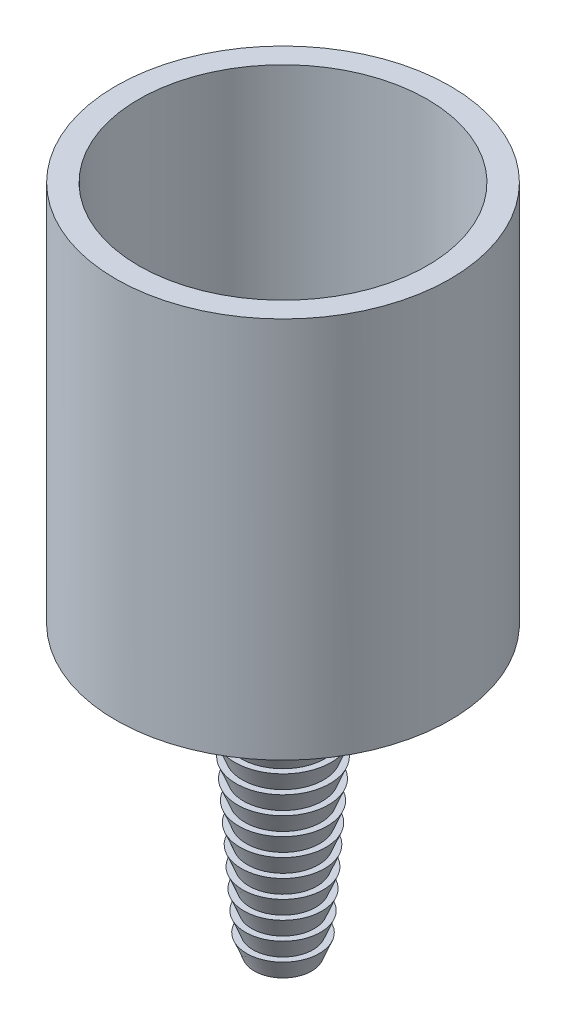
from build123d import *

# Parameters (mm, degrees)
SKETCH_1_R          = 17.5
EXTRUDE_1_DEPTH     = 40
SKETCH_2_R          = 15.1
CUT_EXTRUDE_1_DEPTH = 35
SKETCH_5_R          = 1.75
CUT_EXTRUDE_2_DEPTH = 71
SKETCH_8_R          = 17.5
EXTRUDE_2_DEPTH     = 5
SKETCH_11_R         = 1
CUT_EXTRUDE_3_DEPTH = 5


with BuildPart() as part:
    # 草图1 → 凸台-拉伸1 (new body)
    with BuildSketch(Plane(origin=(0, 0, 0), x_dir=(1, 0, 0), z_dir=(0, 1, 0))):
        Circle(SKETCH_1_R)
    extrude(amount=EXTRUDE_1_DEPTH)

    # 草图2 → 切除-拉伸1 (cut)
    with BuildSketch(Plane(origin=(0, 40, 0), x_dir=(1, 0, 0), z_dir=(0, 1, 0))):
        Circle(SKETCH_2_R)
    extrude(amount=-CUT_EXTRUDE_1_DEPTH, mode=Mode.SUBTRACT)

    # 草图4 → 旋转1 (revolve)
    with BuildSketch(Plane.XY):
        Polygon((0, 0), (0, -30), (3, -30), (3.8, -28), (3.139853624, -28), (3.939512947, -26.004871899), (3.279366571, -26.004871899), (4.079025895, -24.009743799), (3.418879519, -24.009743799), (4.218538842, -22.014615698), (3.558392466, -22.014615698), (4.35805179, -20.019487598), (3.697905414, -20.019487598), (4.497564737, -18.024359497), (3.837418361, -18.024359497), (4.637077685, -16.029231397), (3.976931309, -16.029231397), (4.776590632, -14.034103296), (4.116444256, -14.034103296), (4.91610358, -12.038975196), (4.255957204, -12.038975196), (5.055616527, -10.043847095), (4.395470151, -10.043847095), (5.195129475, -8.048718995), (4.534983099, -8.048718995), (5.334642422, -6.053590894), (4.674496046, -6.053590894), (5.47415537, -4.058462794), (4.814008994, -4.058462794), (17.5, 0), align=None)
    revolve(axis=Axis((0, 0, 0), (0, -1, 0)))

    # 草图5 → 切除-拉伸2 (cut, through all)
    with BuildSketch(Plane.XZ.offset(30)):
        Circle(SKETCH_5_R)
    extrude(amount=-CUT_EXTRUDE_2_DEPTH, mode=Mode.SUBTRACT)

    # 草图8 → 凸台-拉伸2 (add)
    with BuildSketch(Plane(origin=(0, 10, 0), x_dir=(1, 0, 0), z_dir=(0, 1, 0))):
        Circle(SKETCH_8_R)
    extrude(amount=EXTRUDE_2_DEPTH)

    # 草图11 → 切除-拉伸3 (cut)
    with BuildSketch(Plane(origin=(0, 15, 0), x_dir=(1, 0, 0), z_dir=(0, 1, 0))):
        with Locations((0, 9)):
            Circle(SKETCH_11_R)
        with Locations((3.660629788, 8.221909119)):
            Circle(SKETCH_11_R)
        with Locations((6.688303429, 6.022175457)):
            Circle(SKETCH_11_R)
        with Locations((8.559508647, 2.781152949)):
            Circle(SKETCH_11_R)
        with Locations((8.950697058, -0.940756169)):
            Circle(SKETCH_11_R)
        with Locations((7.794228634, -4.5)):
            Circle(SKETCH_11_R)
        with Locations((5.290067271, -7.281152949)):
            Circle(SKETCH_11_R)
        with Locations((1.871205217, -8.803328407)):
            Circle(SKETCH_11_R)
        with Locations((-1.871205217, -8.803328407)):
            Circle(SKETCH_11_R)
        with Locations((-5.290067271, -7.281152949)):
            Circle(SKETCH_11_R)
        with Locations((-7.794228634, -4.5)):
            Circle(SKETCH_11_R)
        with Locations((-8.950697058, -0.940756169)):
            Circle(SKETCH_11_R)
        with Locations((-8.559508647, 2.781152949)):
            Circle(SKETCH_11_R)
        with Locations((-6.688303429, 6.022175457)):
            Circle(SKETCH_11_R)
        with Locations((-3.660629788, 8.221909119)):
            Circle(SKETCH_11_R)
        with Locations((0, 12.5)):
            Circle(SKETCH_11_R)
        with Locations((3.10862359, 12.107289514)):
            Circle(SKETCH_11_R)
        with Locations((6.021920926, 10.953833501)):
            Circle(SKETCH_11_R)
        with Locations((8.556838824, 9.112107843)):
            Circle(SKETCH_11_R)
        with Locations((10.554099069, 6.697834937)):
            Circle(SKETCH_11_R)
        with Locations((11.888206454, 3.86271243)):
            Circle(SKETCH_11_R)
        with Locations((12.475334105, 0.784881494)):
            Circle(SKETCH_11_R)
        with Locations((12.278590634, -2.342266432)):
            Circle(SKETCH_11_R)
        with Locations((11.310338156, -5.322241145)):
            Circle(SKETCH_11_R)
        with Locations((9.631415535, -7.967799872)):
            Circle(SKETCH_11_R)
        with Locations((7.347315654, -10.11271243)):
            Circle(SKETCH_11_R)
        with Locations((4.601556909, -11.622206074)):
            Circle(SKETCH_11_R)
        with Locations((1.56666542, -12.401433766)):
            Circle(SKETCH_11_R)
        with Locations((-1.56666542, -12.401433766)):
            Circle(SKETCH_11_R)
        with Locations((-4.601556909, -11.622206074)):
            Circle(SKETCH_11_R)
        with Locations((-7.347315654, -10.11271243)):
            Circle(SKETCH_11_R)
        with Locations((-9.631415535, -7.967799872)):
            Circle(SKETCH_11_R)
        with Locations((-11.310338156, -5.322241145)):
            Circle(SKETCH_11_R)
        with Locations((-12.278590634, -2.342266432)):
            Circle(SKETCH_11_R)
        with Locations((-12.475334105, 0.784881494)):
            Circle(SKETCH_11_R)
        with Locations((-11.888206454, 3.86271243)):
            Circle(SKETCH_11_R)
        with Locations((-10.554099069, 6.697834937)):
            Circle(SKETCH_11_R)
        with Locations((-8.556838824, 9.112107843)):
            Circle(SKETCH_11_R)
        with Locations((-6.021920926, 10.953833501)):
            Circle(SKETCH_11_R)
        with Locations((-3.10862359, 12.107289514)):
            Circle(SKETCH_11_R)
    extrude(amount=-CUT_EXTRUDE_3_DEPTH, mode=Mode.SUBTRACT)


solid = part.part
